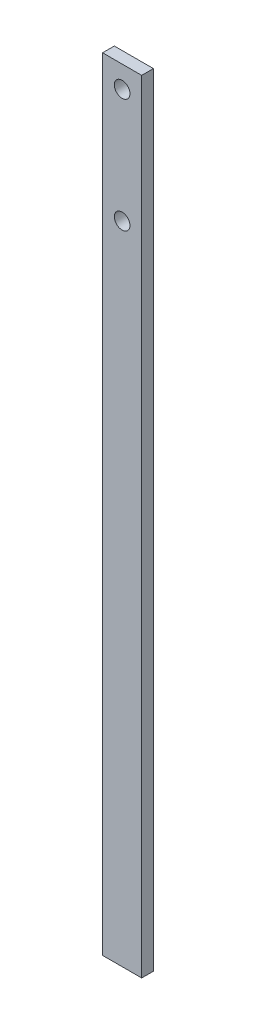
from build123d import *

# Parameters (mm, degrees)
SKETCH1_W           = 10
SKETCH1_H           = 200
BOSS_EXTRUDE1_DEPTH = 3
SKETCH2_R           = 2
CUT_EXTRUDE1_DEPTH  = 3


with BuildPart() as part:
    # Sketch1 → Boss-Extrude1 (new body)
    with BuildSketch(Plane.XY):
        Rectangle(SKETCH1_W, SKETCH1_H)
    extrude(amount=BOSS_EXTRUDE1_DEPTH)

    # Sketch2 → Cut-Extrude1 (cut)
    with BuildSketch(Plane.XY.offset(3)):
        with Locations((0, 94.402193775)):
            Circle(SKETCH2_R)
        with Locations((0, 65.206234386)):
            Circle(SKETCH2_R)
    extrude(amount=-CUT_EXTRUDE1_DEPTH, mode=Mode.SUBTRACT)


solid = part.part
